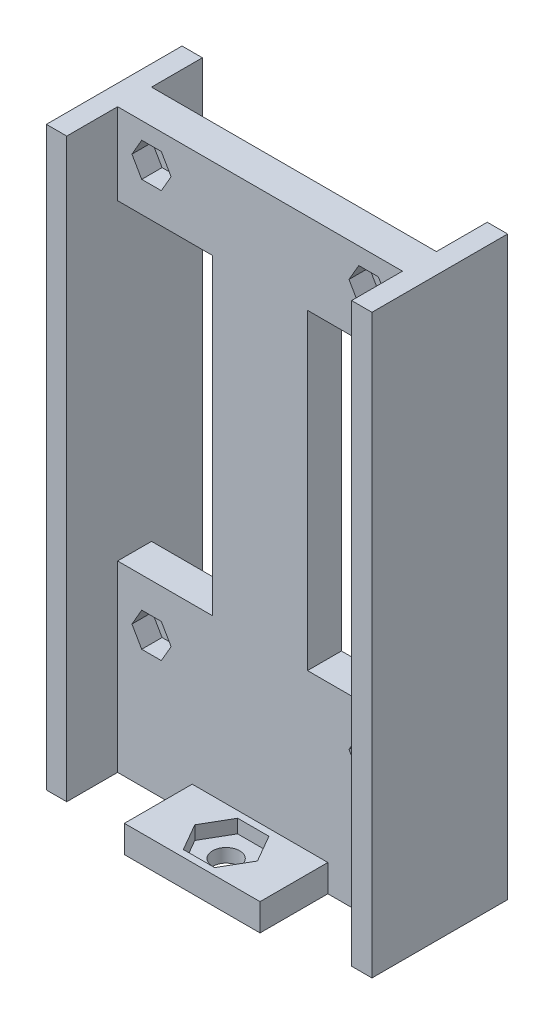
from build123d import *

# Parameters (mm, degrees)
SKETCH1_R                  = 0.8
BRACKETWITHBOLTHOLES_DEPTH = 2.5
SKETCH2_W                  = 10
SKETCH2_H                  = 2
BRACKETEXTENSION_DEPTH     = 2.5
SKETCH2_3_W                = 10
SKETCH2_3_H                = 2
BASE_DEPTH                 = 5
BASE_DEPTH_BACK            = 7.5
SKETCH3_R                  = 1
BASEBOLTHOLES_DEPTH        = 3
SKETCH3_3_R                = 1
BASENUTSLOTS_DEPTH         = 1
SKETCH4_W                  = 1.5
SKETCH4_H                  = 10
STIFFENERRIB_DEPTH         = 42.5
BRACKETNUTSLOTS_DEPTH      = 1.5


with BuildPart() as part:
    # Sketch1 → BracketWithBoltHoles (new body)
    with BuildSketch(Plane.XY):
        Polygon((-10.5, 17.5), (-10.5, 11.5), (-3.5, 11.5), (-3.5, -11.5), (-10.5, -11.5), (-10.5, -17.5), (10.5, -17.5), (10.5, -11.5), (3.5, -11.5), (3.5, 11.5), (10.5, 11.5), (10.5, 17.5), align=None)
        with Locations((-8, -15)):
            Circle(SKETCH1_R, mode=Mode.SUBTRACT)
        with Locations((8, -15)):
            Circle(SKETCH1_R, mode=Mode.SUBTRACT)
        with Locations((-8, 15)):
            Circle(SKETCH1_R, mode=Mode.SUBTRACT)
        with Locations((8, 15)):
            Circle(SKETCH1_R, mode=Mode.SUBTRACT)
    extrude(amount=BRACKETWITHBOLTHOLES_DEPTH)

    # Sketch2 → BracketExtension (add)
    with BuildSketch(Plane.XY.offset(2.5)):
        Polygon((10.5, -17.5), (-10.5, -17.5), (-10.5, -25), (-5, -25), (-5, -23), (5, -23), (5, -25), (10.5, -25), align=None)
        with Locations((0, -24)):
            Rectangle(SKETCH2_W, SKETCH2_H)
    extrude(amount=-BRACKETEXTENSION_DEPTH)

    # Sketch2_3 → Base (add, two sides)
    with BuildSketch(Plane.XY.offset(2.5)) as base_sk:
        with Locations((0, -24)):
            Rectangle(SKETCH2_3_W, SKETCH2_3_H)
    extrude(amount=BASE_DEPTH)
    extrude(base_sk.sketch, amount=-BASE_DEPTH_BACK)

    # Sketch3 → BaseBoltHoles (cut, through all)
    with BuildSketch(Plane(origin=(0, -23, 0), x_dir=(1, 0, 0), z_dir=(0, 1, 0))):
        with Locations((0, -5)):
            Circle(SKETCH3_R)
        with Locations((0, 2.5)):
            Circle(SKETCH3_R)
    extrude(amount=-BASEBOLTHOLES_DEPTH, mode=Mode.SUBTRACT)

    # Sketch3_3 → BaseNutSlots (cut)
    with BuildSketch(Plane(origin=(0, -23, 0), x_dir=(1, 0, 0), z_dir=(0, 1, 0))):
        Polygon((1.154700538, -7), (2.309401077, -5), (1.154700538, -3), (-1.154700538, -3), (-2.309401077, -5), (-1.154700538, -7), align=None)
        with Locations((0, -5)):
            Circle(SKETCH3_3_R, mode=Mode.SUBTRACT)
        Polygon((-1.154700538, 0.5), (-2.309401077, 2.5), (-1.154700538, 4.5), (1.154700538, 4.5), (2.309401077, 2.5), (1.154700538, 0.5), align=None)
        with Locations((0, 2.5)):
            Circle(SKETCH3_3_R, mode=Mode.SUBTRACT)
    extrude(amount=-BASENUTSLOTS_DEPTH, mode=Mode.SUBTRACT)

    # Sketch4 → StiffenerRib (add)
    with BuildSketch(Plane(origin=(0, 17.5, 0), x_dir=(1, 0, 0), z_dir=(0, 1, 0))):
        with Locations((-11.25, -1.25)):
            Rectangle(SKETCH4_W, SKETCH4_H)
    stiffenerrib = extrude(amount=-STIFFENERRIB_DEPTH)

    # StiffenerRib2: StiffenerRib across plane
    add(stiffenerrib.mirror(Plane(origin=(0, 0, 0), x_dir=(0, 0, 1), z_dir=(1, 0, 0))))

    # Sketch5 → BracketNutSlots (cut)
    with BuildSketch(Plane.XY.offset(2.5)):
        Polygon((-7.278312164, 16.25), (-8.721687836, 16.25), (-9.443375673, 15), (-8.721687836, 13.75), (-7.278312164, 13.75), (-6.556624327, 15), align=None)
        Polygon((-7.278312164, -13.75), (-8.721687836, -13.75), (-9.443375673, -15), (-8.721687836, -16.25), (-7.278312164, -16.25), (-6.556624327, -15), align=None)
        Polygon((8.721687836, -16.25), (7.278312164, -16.25), (6.556624327, -15), (7.278312164, -13.75), (8.721687836, -13.75), (9.443375673, -15), align=None)
        Polygon((6.556624327, 15), (7.278312164, 16.25), (8.721687836, 16.25), (9.443375673, 15), (8.721687836, 13.75), (7.278312164, 13.75), align=None)
    extrude(amount=-BRACKETNUTSLOTS_DEPTH, mode=Mode.SUBTRACT)


solid = part.part
